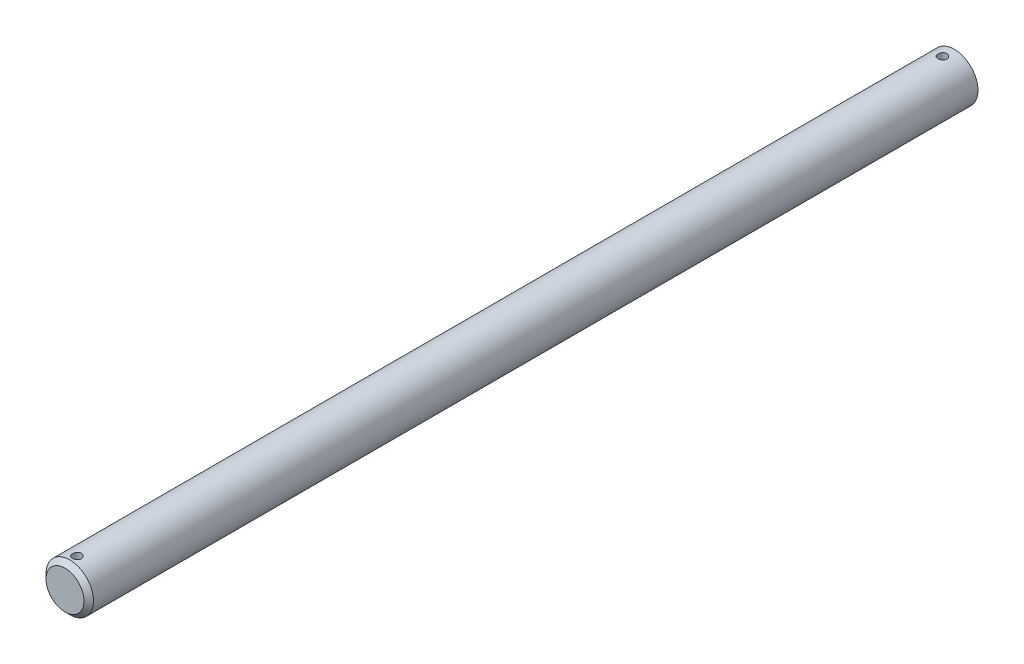
from build123d import *

# Parameters (mm, degrees)
SKETCH3_R               = 3.175
BOSS_EXTRUDE1_DEPTH     = 304.8
CHAMFER1_SIZE           = 0.635
CUT_EXTRUDE1_START      = -118.919625
SKETCH4_R               = 3.175
CUT_EXTRUDE1_DEPTH      = 491.680375
SKETCH5_R               = 0.5953125
CUT_EXTRUDE2_DEPTH      = 4.175
CUT_EXTRUDE2_DEPTH_BACK = 4.175


with BuildPart() as part:
    # Sketch3 → Boss-Extrude1 (new body, symmetric)
    with BuildSketch(Plane.XY):
        Circle(SKETCH3_R)
    extrude(amount=BOSS_EXTRUDE1_DEPTH, both=True)

    # Chamfer1
    chamfer1_edges = [part.edges().sort_by_distance(p)[0] for p in [
        (-3.175, 0, -304.8),
        (-3.175, 0, 304.8),
    ]]
    chamfer(chamfer1_edges, length=CHAMFER1_SIZE)

    # Sketch4 → Cut-Extrude1 (cut, through all)
    with BuildSketch(Plane.XY.offset(304.8).offset(CUT_EXTRUDE1_START)):
        Circle(SKETCH4_R)
    extrude(amount=-CUT_EXTRUDE1_DEPTH, mode=Mode.SUBTRACT)

    # Sketch5 → Cut-Extrude2 (cut, two sides)
    with BuildSketch(Plane(origin=(0, 0, 0), x_dir=(1, 0, 0), z_dir=(0, 1, 0))) as cut_extrude2_sk:
        with Locations((0, -187.467875)):
            Circle(SKETCH5_R)
        with Locations((0, -303.2125)):
            Circle(SKETCH5_R)
    extrude(amount=CUT_EXTRUDE2_DEPTH, mode=Mode.SUBTRACT)
    extrude(cut_extrude2_sk.sketch, amount=-CUT_EXTRUDE2_DEPTH_BACK, mode=Mode.SUBTRACT)


solid = part.part
